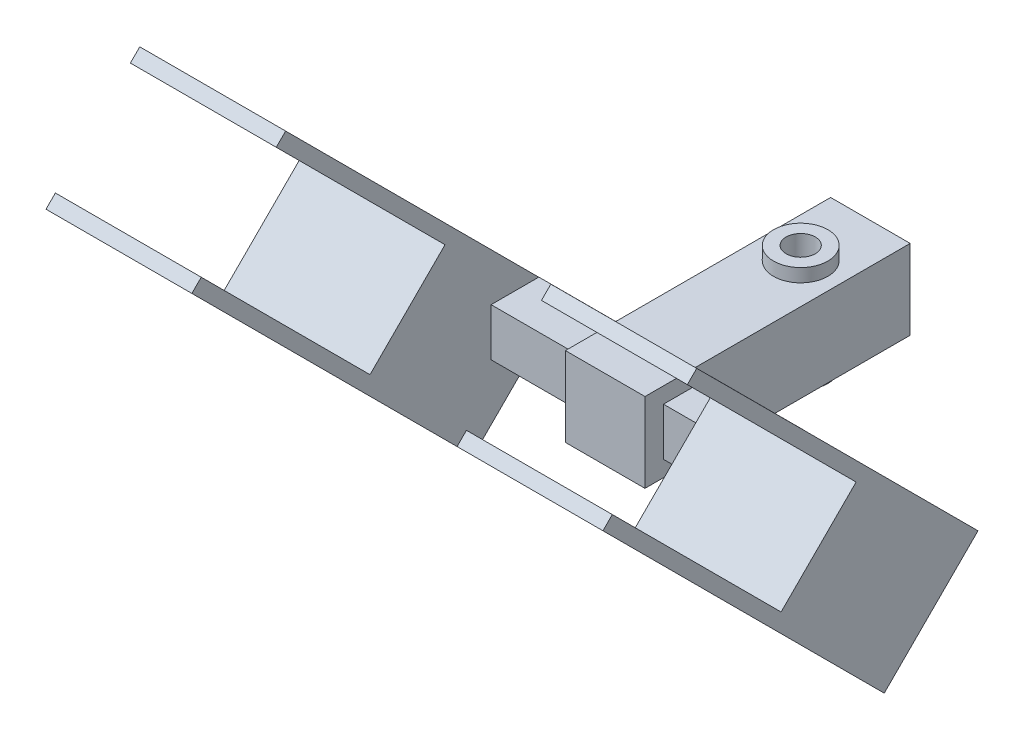
from build123d import *

# Parameters (mm, degrees)
SKETCH_2_W               = 30
SKETCH_2_H               = 30
EXTRUDE_1_DEPTH          = 100
SKETCH_3_W               = 18
SKETCH_3_H               = 18
EXTRUDE_2_DEPTH          = 35
PATTERN_CIRCULAR_1_COUNT = 2
SKETCH_4_R               = 10.254249717
EXTRUDE_4_DEPTH          = 5
SKETCH_5_R               = 5.5
CUT_EXTRUDE_2_DEPTH      = 15
PATTERN_CIRCULAR_3_COUNT = 2
PATTERN_CIRCULAR_4_COUNT = 2
EXTRUDE_5_DEPTH          = 55
PATTERN_LINEAR_1_COUNT   = 2
PATTERN_LINEAR_1_PITCH   = 155
SKETCH_7_W               = 55
SKETCH_7_H               = 5
EXTRUDE_6_DEPTH          = 90


with BuildPart() as part:
    # 草图2 → 凸台-拉伸1 (new body)
    with BuildSketch(Plane.XY):
        Rectangle(SKETCH_2_W, SKETCH_2_H)
    extrude(amount=EXTRUDE_1_DEPTH)

    # 草图3 → 凸台-拉伸2 (add)
    with BuildSketch(Plane(origin=(15, 0, 0), x_dir=(0, 0, -1), z_dir=(1, 0, 0))):
        with Locations((-84.019000904, 0)):
            Rectangle(SKETCH_3_W, SKETCH_3_H)
    extrude_2 = extrude(amount=EXTRUDE_2_DEPTH)

    # 阵列(圆周)1: 凸台-拉伸2 ×2 about axis
    pattern_circular_1_axis = Axis((0, 0, 0), (0, 0, 1))
    for i in range(1, PATTERN_CIRCULAR_1_COUNT):
        add(extrude_2.rotate(pattern_circular_1_axis, i * 360 / PATTERN_CIRCULAR_1_COUNT))

    # 草图4 → 凸台-拉伸4 (add)
    with BuildSketch(Plane(origin=(0, 15, 0), x_dir=(1, 0, 0), z_dir=(0, 1, 0))):
        with Locations((0, -26.28538531)):
            Circle(SKETCH_4_R)
    extrude_4 = extrude(amount=EXTRUDE_4_DEPTH)

    # 草图5 → 切除-拉伸2 (cut)
    with BuildSketch(Plane(origin=(0, 20, 0), x_dir=(1, 0, 0), z_dir=(0, 1, 0))):
        with Locations((0, -26.28538531)):
            Circle(SKETCH_5_R)
    cut_extrude_2 = extrude(amount=-CUT_EXTRUDE_2_DEPTH, mode=Mode.SUBTRACT)

    # 阵列(圆周)3: 凸台-拉伸4 ×2 about axis
    pattern_circular_3_axis = Axis((0, 0, 100), (0, 0, -1))
    for i in range(1, PATTERN_CIRCULAR_3_COUNT):
        add(extrude_4.rotate(pattern_circular_3_axis, i * 360 / PATTERN_CIRCULAR_3_COUNT))

    # 阵列(圆周)4: 切除-拉伸2 ×2 about axis
    pattern_circular_4_axis = Axis((0, 0, 100), (0, 0, -1))
    for i in range(1, PATTERN_CIRCULAR_4_COUNT):
        add(cut_extrude_2.rotate(pattern_circular_4_axis, i * 360 / PATTERN_CIRCULAR_4_COUNT), mode=Mode.SUBTRACT)

    # 草图6 → 凸台-拉伸5 (add)
    with BuildSketch(Plane(origin=(50, 0, 0), x_dir=(0, 0, -1), z_dir=(1, 0, 0))):
        Polygon((-64.431978069, -1.626144526), (-106.85838494, 40.800262345), (-142.213724, 5.444923286), (-99.787317129, -36.981483585), align=None)
    extrude_5 = extrude(amount=EXTRUDE_5_DEPTH)

    # 阵列(线性)1: 凸台-拉伸5 ×2
    with Locations(*[(-i * PATTERN_LINEAR_1_PITCH, 0, 0) for i in range(1, PATTERN_LINEAR_1_COUNT)]):
        add(extrude_5)

    # 草图7 → 凸台-拉伸6 (add)
    with BuildSketch(Plane(origin=(0, 73.829323643, 73.829323643), x_dir=(1, 0, 0), z_dir=(0, 0.707106781, 0.707106781))):
        with Locations((77.5, -94.21014644)):
            Rectangle(SKETCH_7_W, SKETCH_7_H)
        with Locations((77.5, -49.21014644)):
            Rectangle(SKETCH_7_W, SKETCH_7_H)
        with Locations((-77.5, -94.21014644)):
            Rectangle(SKETCH_7_W, SKETCH_7_H)
        with Locations((-77.5, -49.21014644)):
            Rectangle(SKETCH_7_W, SKETCH_7_H)
    extrude(amount=EXTRUDE_6_DEPTH)


solid = part.part
